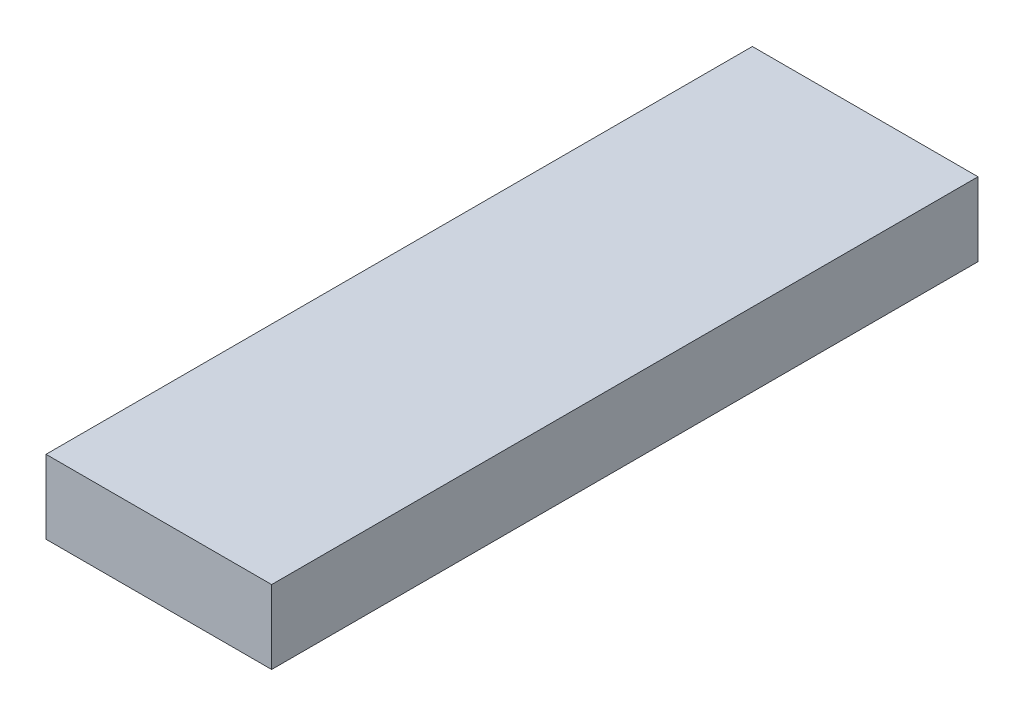
from build123d import *

# Parameters (mm, degrees)
SKETCH1_W  = 46
SKETCH1_H  = 144
CELL_DEPTH = 15


with BuildPart() as part:
    # Sketch1 → cell (new body)
    with BuildSketch(Plane(origin=(0, 0, 0), x_dir=(1, 0, 0), z_dir=(0, 1, 0))):
        Rectangle(SKETCH1_W, SKETCH1_H)
    extrude(amount=CELL_DEPTH)


solid = part.part
